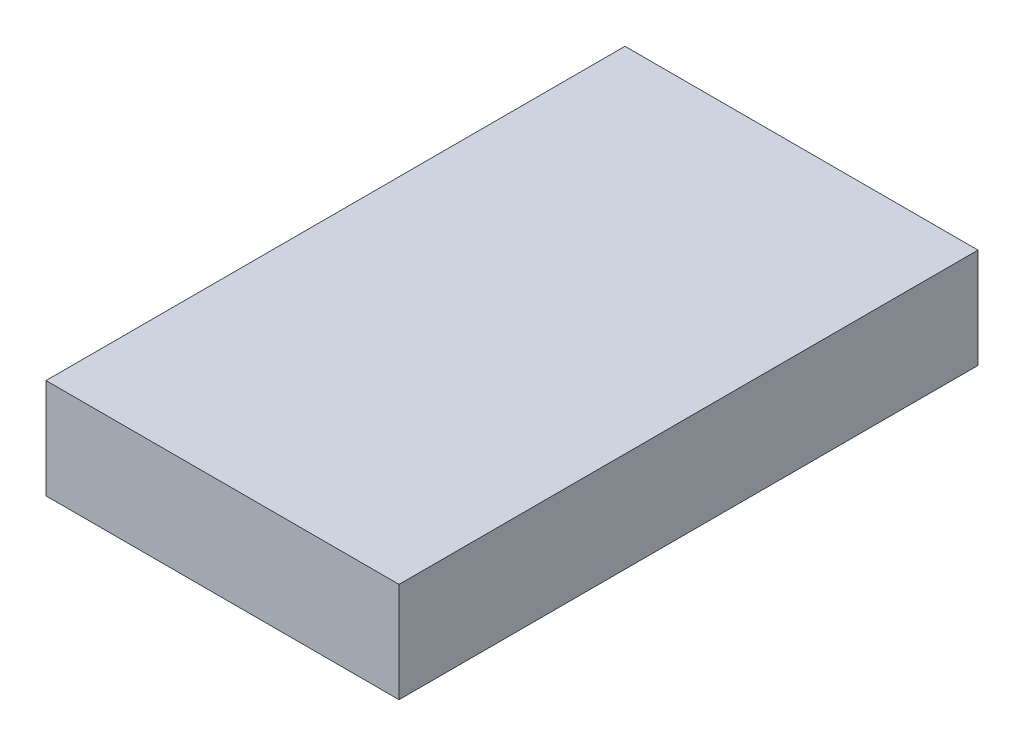
from build123d import *

# Parameters (mm, degrees)
SKETCH1_W           = 50
SKETCH1_H           = 82
BOSS_EXTRUDE1_DEPTH = 14.15


with BuildPart() as part:
    # Sketch1 → Boss-Extrude1 (new body)
    with BuildSketch(Plane(origin=(0, 0, 0), x_dir=(1, 0, 0), z_dir=(0, 1, 0))):
        with Locations((25, -41)):
            Rectangle(SKETCH1_W, SKETCH1_H)
    extrude(amount=BOSS_EXTRUDE1_DEPTH)


solid = part.part
